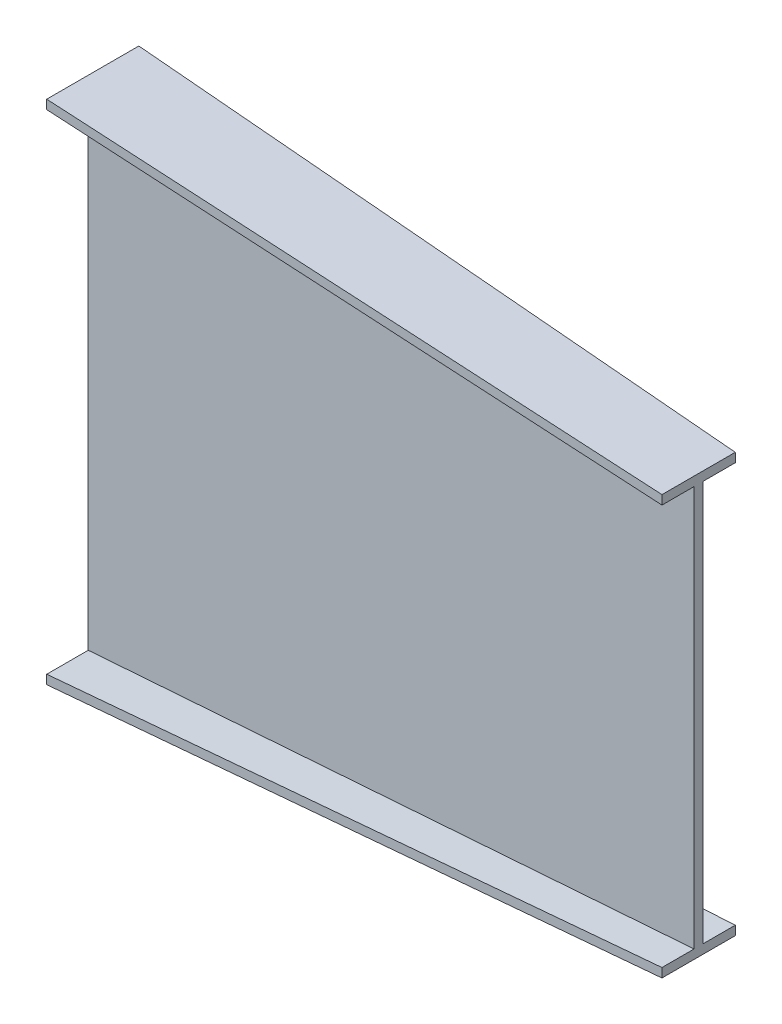
from build123d import *


with BuildPart() as part:
    # Sketch1 → Loft l2 section 0
    with BuildSketch(Plane(origin=(0, 0, 0), x_dir=(0, 0, -1), z_dir=(1, 0, 0))):
        Polygon((-83.5, 418.5), (68.5, 418.5), (68.5, 403.5), (0, 403.5), (0, -403.5), (68.5, -403.5), (68.5, -418.5), (-83.5, -418.5), (-83.5, -403.5), (-15, -403.5), (-15, 403.5), (-83.5, 403.5), align=None)
    # Sketch4 → Loft l2 section 1
    with BuildSketch(Plane(origin=(1000, 0, -1000), x_dir=(0, 0, 1), z_dir=(-1, 0, 0))):
        Polygon((947, 345.5), (1068, 345.5), (1068, 330.5), (1015, 330.5), (1015, -330.5), (1068, -330.5), (1068, -345.5), (947, -345.5), (947, -330.5), (1000, -330.5), (1000, 330.5), (947, 330.5), align=None)
    loft()


solid = part.part
